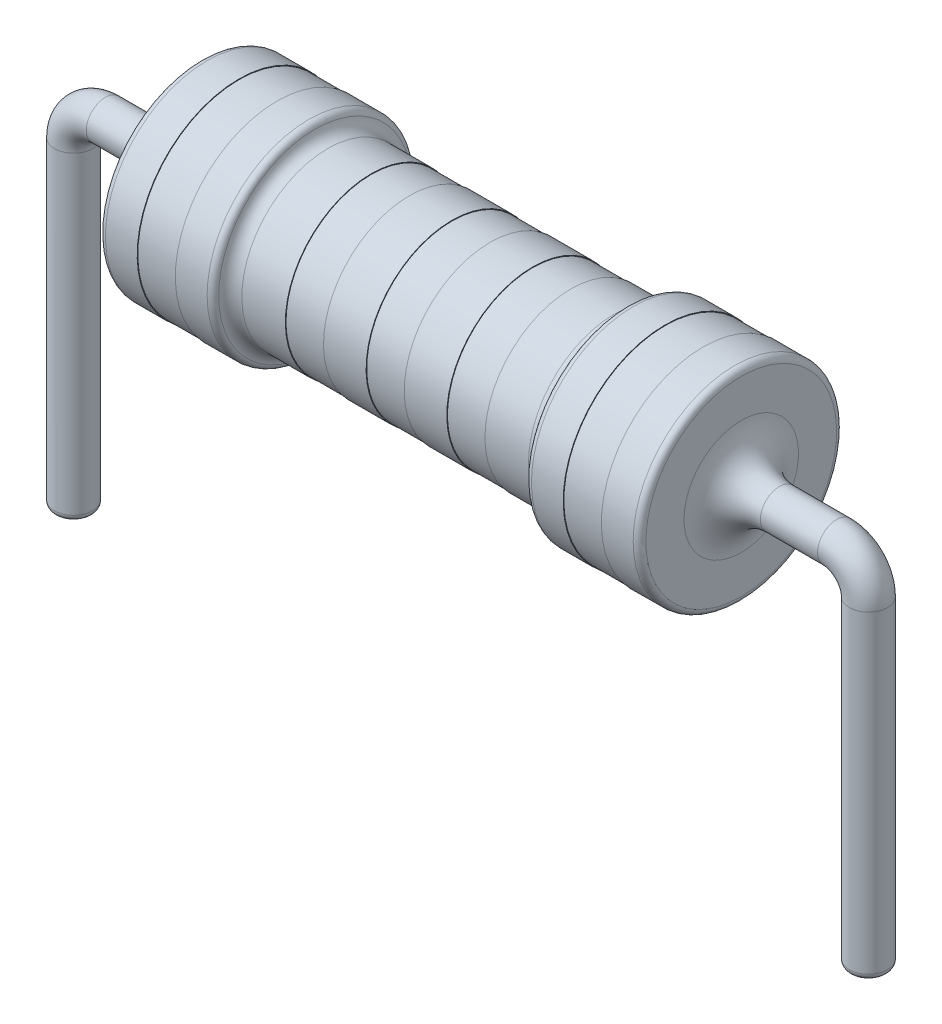
from build123d import *

# Parameters (mm, degrees)
SKETCH3_R  = 0.3
FILLET10_R = 0.1
FILLET11_R = 0.2
FILLET12_R = 0.6
FILLET13_R = 0.1


with BuildPart() as part:
    # Sketch1 → Revolve2 (revolve)
    with BuildSketch(Plane.XY):
        Polygon((4.25, 0), (-4.25, 0), (-4.25, -1.6), (-3.65, -1.6), (-3.65, -1.59), (-3.05, -1.59), (-3.05, -1.6), (-2.45, -1.6), (-2.45, -1.35), (-1.569520407, -1.35), (-1.569520407, -1.34), (-0.969520407, -1.34), (-0.969520407, -1.35), (-0.3, -1.35), (-0.3, -1.34), (0.3, -1.34), (0.3, -1.35), (0.969520407, -1.35), (0.969520407, -1.34), (1.569520407, -1.34), (1.569520407, -1.35), (2.45, -1.35), (2.45, -1.6), (3.05, -1.6), (3.05, -1.59), (3.65, -1.59), (3.65, -1.6), (4.25, -1.6), align=None)
    revolve(axis=Axis((4.25, 0, 0), (-1, 0, 0)))

    # Sweep2: sweep along a curve in space
    with BuildLine() as sweep2_path:
        Line((4.25, 0, 0), (5.75, 0, 0))
        ThreePointArc((6.25, -0.5, 0), (6.103553391, -0.146446609, 0), (5.75, 0, 0))
        Line((6.25, -0.5, 0), (6.25, -5.530842592, 0))
    # Sketch3 → Sweep2 (sweep)
    with BuildSketch(Plane(origin=(4.25, 0, 0), x_dir=(0, 0, -1), z_dir=(1, 0, 0))):
        Circle(SKETCH3_R)
    sweep2 = sweep(path=sweep2_path.line)

    # Mirror2: Sweep2 across plane
    add(sweep2.mirror(Plane(origin=(0, 0, 0), x_dir=(0, 0, 1), z_dir=(1, 0, 0))))

    # Fillet10
    fillet10_edges = [part.edges().sort_by_distance(p)[0] for p in [
        (2.45, 1.6, 0),
        (4.25, 1.6, 0),
        (-4.25, 1.6, 0),
        (-2.45, 1.6, 0),
    ]]
    fillet(fillet10_edges, radius=FILLET10_R)

    # Fillet11
    fillet11_edges = [part.edges().sort_by_distance(p)[0] for p in [
        (2.45, 1.35, 0),
        (-2.45, 1.35, 0),
    ]]
    fillet(fillet11_edges, radius=FILLET11_R)

    # Fillet12
    fillet12_edges = [part.edges().sort_by_distance(p)[0] for p in [
        (4.25, 0, 0.3),
        (-4.25, 0, 0.3),
    ]]
    fillet(fillet12_edges, radius=FILLET12_R)

    # Fillet13
    fillet13_edges = [part.edges().sort_by_distance(p)[0] for p in [
        (6.25, -5.530842592, 0.3),
        (-6.25, -5.530842592, 0.3),
    ]]
    fillet(fillet13_edges, radius=FILLET13_R)


solid = part.part
